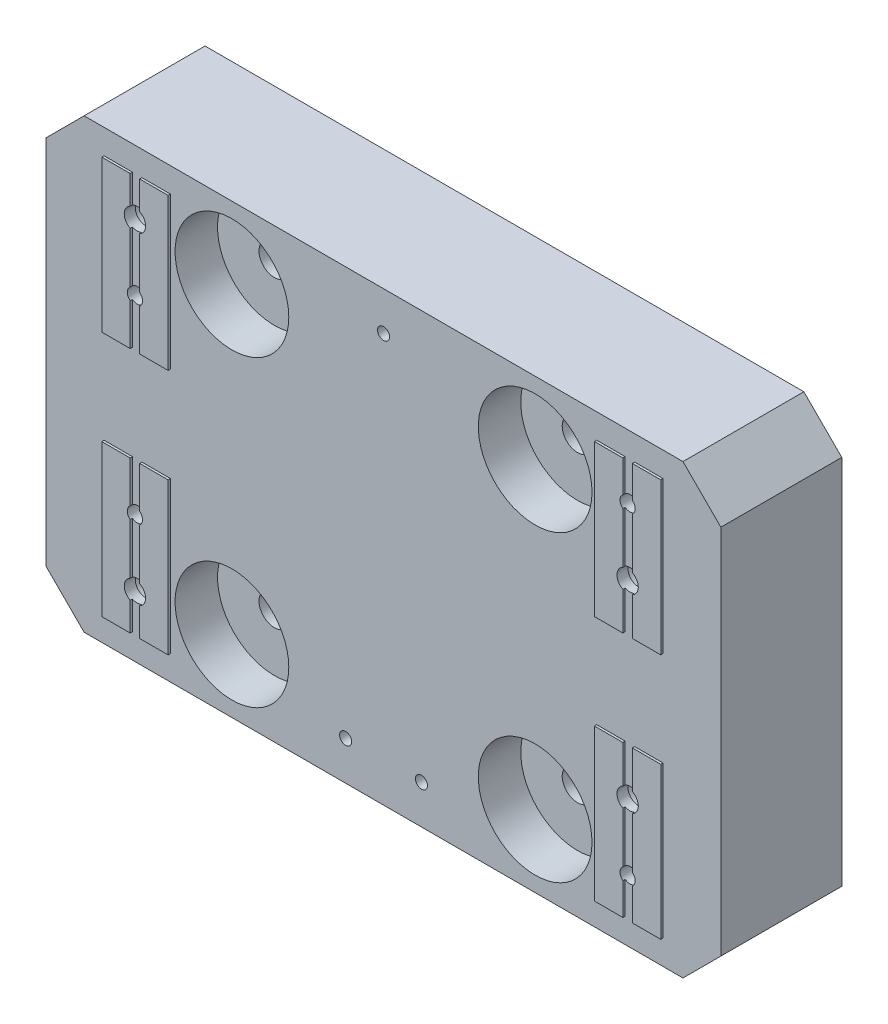
from build123d import *

# Parameters (mm, degrees)
SKETCH3_W                                        = 226.06
SKETCH3_H                                        = 149.86
EXTRUDE2_DEPTH                                   = 41.275
SKETCH4_W                                        = 226.06
SKETCH4_H                                        = 149.86
SKETCH4_W_2                                      = 22.225
SKETCH4_H_2                                      = 50.8
EXTRUDE4_DEPTH                                   = 0.762
CBORE_FOR_1_4_SOCKET_HEAD_CAP_SCREW1_AT_COUNT    = 2
CBORE_FOR_1_4_SOCKET_HEAD_CAP_SCREW1_AT_PITCH    = 186.028991356
CBORE_FOR_1_4_SOCKET_HEAD_CAP_SCREW1_2_COUNT     = 2
CBORE_FOR_1_4_SOCKET_HEAD_CAP_SCREW1_2_PITCH     = 166.589197204
CBORE_FOR_1_4_SOCKET_HEAD_CAP_SCREW1_3_COUNT     = 2
CBORE_FOR_1_4_SOCKET_HEAD_CAP_SCREW1_3_PITCH     = 63.5
F_1_4_20_TAPPED_HOLE1_D                          = 5.1054
CBORE_FOR_3_8_SOCKET_HEAD_CAP_SCREW1_D           = 10.31748
CBORE_FOR_3_8_SOCKET_HEAD_CAP_SCREW1_CBORE_D     = 38.1
CBORE_FOR_3_8_SOCKET_HEAD_CAP_SCREW1_CBORE_DEPTH = 14.224
SKETCH18_W                                       = 3.175
SKETCH18_H                                       = 133.35
CUT_EXTRUDE1_DEPTH                               = 0.762
F_10_32_TAPPED_HOLE1_D                           = 4.0386
CHAMFER1_SIZE                                    = 12.7


with BuildPart() as part:
    # Sketch3 → Extrude2 (new body)
    with BuildSketch(Plane.XY):
        with Locations((113.03, -74.93)):
            Rectangle(SKETCH3_W, SKETCH3_H)
    extrude(amount=EXTRUDE2_DEPTH)

    # Sketch4 → Extrude4 (cut)
    with BuildSketch(Plane.XY.offset(41.275)):
        with Locations((113.03, -74.93)):
            Rectangle(SKETCH4_W, SKETCH4_H)
        with Locations((30.4927, -33.655)):
            Rectangle(SKETCH4_W_2, SKETCH4_H_2, mode=Mode.SUBTRACT)
        with Locations((195.5673, -33.655)):
            Rectangle(SKETCH4_W_2, SKETCH4_H_2, mode=Mode.SUBTRACT)
        with Locations((30.4927, -116.205)):
            Rectangle(SKETCH4_W_2, SKETCH4_H_2, mode=Mode.SUBTRACT)
        with Locations((195.5673, -116.205)):
            Rectangle(SKETCH4_W_2, SKETCH4_H_2, mode=Mode.SUBTRACT)
    extrude(amount=-EXTRUDE4_DEPTH, mode=Mode.SUBTRACT)

    # Sketch9 → CBORE for 1/4 Socket Head Cap Screw1 (revolve, cut)
    with BuildSketch(Plane(origin=(195.58, -106.68, 0), x_dir=(0, 1, 0), z_dir=(1, 0, 0))):
        Polygon((0, 0), (0, 41.275), (3.57124, 41.275), (3.57124, 37.592), (5.55625, 37.592), (5.55625, 0.635), (6.19125, 0), align=None)
    cbore_for_1_4_socket_head_cap_screw1 = revolve(axis=Axis((195.58, -106.68, -6.35), (0, 0, 1)), mode=Mode.SUBTRACT)

    # CBORE for 1/4 Socket Head Cap Screw1 at: CBORE for 1/4 Socket Head Cap Screw1 ×2
    with Locations(*[Vector(-0.887496077, 0.460815271, 0) * (i * CBORE_FOR_1_4_SOCKET_HEAD_CAP_SCREW1_AT_PITCH) for i in range(1, CBORE_FOR_1_4_SOCKET_HEAD_CAP_SCREW1_AT_COUNT)]):
        add(cbore_for_1_4_socket_head_cap_screw1, mode=Mode.SUBTRACT)

    # CBORE for 1_4 Socket Head Cap Screw1 2: CBORE for 1/4 Socket Head Cap Screw1 ×2
    with Locations(*[Vector(-0.991060662, -0.133412012, 0) * (i * CBORE_FOR_1_4_SOCKET_HEAD_CAP_SCREW1_2_PITCH) for i in range(1, CBORE_FOR_1_4_SOCKET_HEAD_CAP_SCREW1_2_COUNT)]):
        add(cbore_for_1_4_socket_head_cap_screw1, mode=Mode.SUBTRACT)

    # CBORE for 1_4 Socket Head Cap Screw1 3: CBORE for 1/4 Socket Head Cap Screw1 ×2
    with Locations(*[(0, i * CBORE_FOR_1_4_SOCKET_HEAD_CAP_SCREW1_3_PITCH, 0) for i in range(1, CBORE_FOR_1_4_SOCKET_HEAD_CAP_SCREW1_3_COUNT)]):
        add(cbore_for_1_4_socket_head_cap_screw1, mode=Mode.SUBTRACT)

    # 1/4-20 Tapped Hole1 (through all)
    with Locations(Plane(origin=(0, 0, 0), x_dir=(-1, 0, 0), z_dir=(0, 0, -1))):
        with Locations((-195.58, -20.955), (-195.58, -128.905), (-30.48, -43.18), (-30.48, -106.68)):
            Hole(F_1_4_20_TAPPED_HOLE1_D / 2)

    # CBORE for 3/8 Socket Head Cap Screw1 (through all)
    with Locations(Plane.XY.offset(40.513)):
        with Locations((163.83, -125.73), (62.23, -125.73), (163.83, -24.13), (62.23, -24.13)):
            CounterBoreHole(CBORE_FOR_3_8_SOCKET_HEAD_CAP_SCREW1_D / 2, CBORE_FOR_3_8_SOCKET_HEAD_CAP_SCREW1_CBORE_D / 2, CBORE_FOR_3_8_SOCKET_HEAD_CAP_SCREW1_CBORE_DEPTH)

    # Sketch18 → Cut-Extrude1 (cut)
    with BuildSketch(Plane.XY.offset(41.275)):
        with Locations((30.48, -74.93)):
            Rectangle(SKETCH18_W, SKETCH18_H)
        with Locations((195.58, -74.93)):
            Rectangle(SKETCH18_W, SKETCH18_H)
    extrude(amount=-CUT_EXTRUDE1_DEPTH, mode=Mode.SUBTRACT)

    # #10-32 Tapped Hole1 (through all)
    with Locations(Plane(origin=(0, 0, 0), x_dir=(-1, 0, 0), z_dir=(0, 0, -1))):
        with Locations((-113.03, -13.0048), (-100.33, -136.8552), (-125.73, -136.8552)):
            Hole(F_10_32_TAPPED_HOLE1_D / 2)

    # Chamfer1
    chamfer1_edges = [part.edges().sort_by_distance(p)[0] for p in [
        (0, 0, 20.2565),
        (226.06, 0, 20.2565),
        (226.06, -149.86, 20.2565),
        (0, -149.86, 20.2565),
    ]]
    chamfer(chamfer1_edges, length=CHAMFER1_SIZE)


solid = part.part
